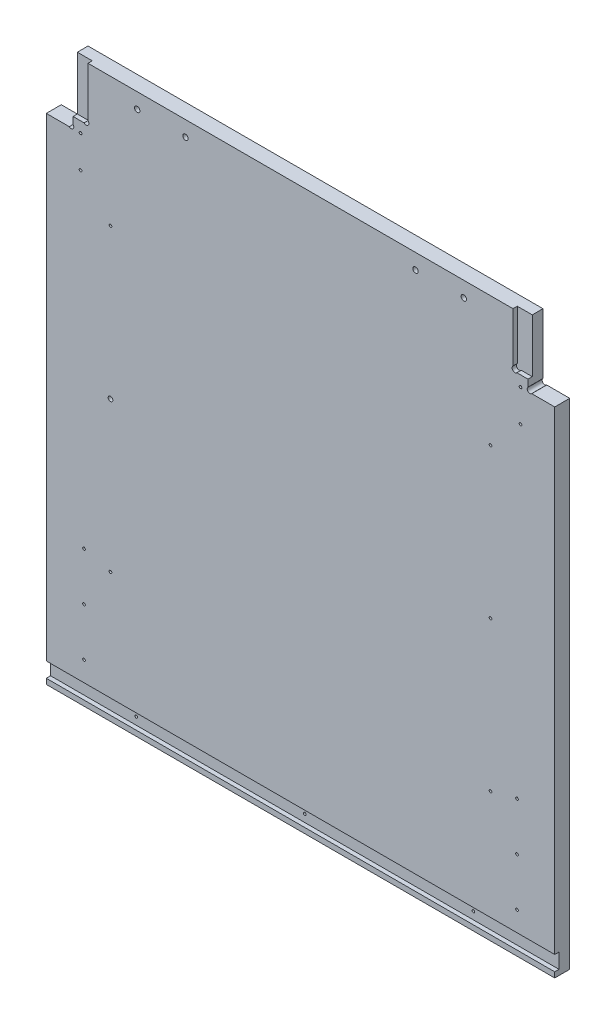
from build123d import *

# Parameters (mm, degrees)
CABBACK_THICKNESS_DEPTH = 17.78
SKETCH4_R               = 3.175000003
SKETCH4_R_2             = 3.175000002
CUT_EXTRUDE1_DEPTH      = 17.78
SKETCH6_R               = 1.5875
SKETCH6_R_2             = 1.587500002
SKETCH6_R_3             = 2.777849083
CUT_EXTRUDE3_DEPTH      = 17.78
CABBACK_LEDGECUTS_W     = 17.78
CABBACK_LEDGECUTS_H     = 63.5
LEDGECUTS_DEPTH_DEPTH   = 5.08
SKETCH7_R               = 3.302
SKETCH7_R_2             = 3.302000002
CUT_EXTRUDE4_DEPTH      = 5.08
SKETCH9_R               = 3.175
CUT_EXTRUDE5_DEPTH      = 17.78


with BuildPart() as part:
    # CabBack_Outline → CabBack_Thickness (new body)
    with BuildSketch(Plane.XY):
        Polygon((10806.641666666, -6342.0625), (11409.891666666, -6342.0625), (11409.891666666, -5755.3225), (11378.141666665, -5755.3225), (11378.141666665, -5679.1225), (10838.391666667, -5679.1225), (10838.391666667, -5755.3225), (10806.641666666, -5755.3225), align=None)
    extrude(amount=-CABBACK_THICKNESS_DEPTH)

    # Sketch4 → Cut-Extrude1 (cut)
    with BuildSketch(Plane.XY):
        with Locations((11380.386730695, -5753.07743597)):
            Circle(SKETCH4_R)
        with Locations((10836.146602637, -5753.07743597)):
            Circle(SKETCH4_R_2)
    extrude(amount=-CUT_EXTRUDE1_DEPTH, mode=Mode.SUBTRACT)

    # Sketch6 → Cut-Extrude3 (cut)
    with BuildSketch(Plane.XY):
        with Locations((10851.409166666, -6294.4375)):
            Circle(SKETCH6_R)
        with Locations((10908.241666666, -6326.8225)):
            Circle(SKETCH6_R)
        with Locations((11108.266666666, -6326.8225)):
            Circle(SKETCH6_R)
        with Locations((11308.291666666, -6326.8225)):
            Circle(SKETCH6_R)
        with Locations((11365.124166666, -6294.4375)):
            Circle(SKETCH6_R)
        with Locations((11365.124166666, -6237.2875)):
            Circle(SKETCH6_R)
        with Locations((11333.691666666, -6188.3925)):
            Circle(SKETCH6_R)
        with Locations((11365.124166666, -6180.1375)):
            Circle(SKETCH6_R)
        with Locations((11333.691666666, -6010.5925)):
            Circle(SKETCH6_R)
        with Locations((11333.691666666, -5832.7925)):
            Circle(SKETCH6_R)
        with Locations((11369.251666663, -5793.344238991)):
            Circle(SKETCH6_R_2)
        with Locations((11369.251666663, -5755.236838581)):
            Circle(SKETCH6_R_2)
        with Locations((10847.281666666, -5755.236838581)):
            Circle(SKETCH6_R)
        with Locations((10847.281666666, -5793.344238991)):
            Circle(SKETCH6_R)
        with Locations((10882.841666666, -6010.5925)):
            Circle(SKETCH6_R_3)
        with Locations((10851.409166666, -6180.1375)):
            Circle(SKETCH6_R)
        with Locations((10882.841666666, -6188.3925)):
            Circle(SKETCH6_R)
        with Locations((10851.409166666, -6237.2875)):
            Circle(SKETCH6_R)
        with Locations((10882.841666666, -5832.7925)):
            Circle(SKETCH6_R)
    extrude(amount=-CUT_EXTRUDE3_DEPTH, mode=Mode.SUBTRACT)

    # CabBack_LedgeCuts → LedgeCuts_Depth (cut)
    with BuildSketch(Plane.XY):
        Polygon((11108.266666666, -6317.9325), (10806.641666666, -6317.9325), (10806.641666666, -6335.7125), (11409.891666666, -6335.7125), (11409.891666666, -6317.9325), align=None)
        with Locations((10847.281666667, -5710.8725)):
            Rectangle(CABBACK_LEDGECUTS_W, CABBACK_LEDGECUTS_H)
        with Locations((11369.251666665, -5710.8725)):
            Rectangle(CABBACK_LEDGECUTS_W, CABBACK_LEDGECUTS_H)
    extrude(amount=-LEDGECUTS_DEPTH_DEPTH, mode=Mode.SUBTRACT)

    # Sketch7 → Cut-Extrude4 (cut)
    with BuildSketch(Plane.XY):
        with Locations((10853.926602637, -5740.37743597)):
            Circle(SKETCH7_R)
        with Locations((11362.606730695, -5740.37743597)):
            Circle(SKETCH7_R_2)
    extrude(amount=-CUT_EXTRUDE4_DEPTH, mode=Mode.SUBTRACT)

    # Sketch9 → Cut-Extrude5 (cut)
    with BuildSketch(Plane.XY):
        with Locations((10914.541654066, -5697.2299822)):
            Circle(SKETCH9_R)
        with Locations((10971.741666666, -5697.2299822)):
            Circle(SKETCH9_R)
        with Locations((11244.741654066, -5697.2299822)):
            Circle(SKETCH9_R)
        with Locations((11301.941666666, -5697.2299822)):
            Circle(SKETCH9_R)
    extrude(amount=-CUT_EXTRUDE5_DEPTH, mode=Mode.SUBTRACT)


solid = part.part
